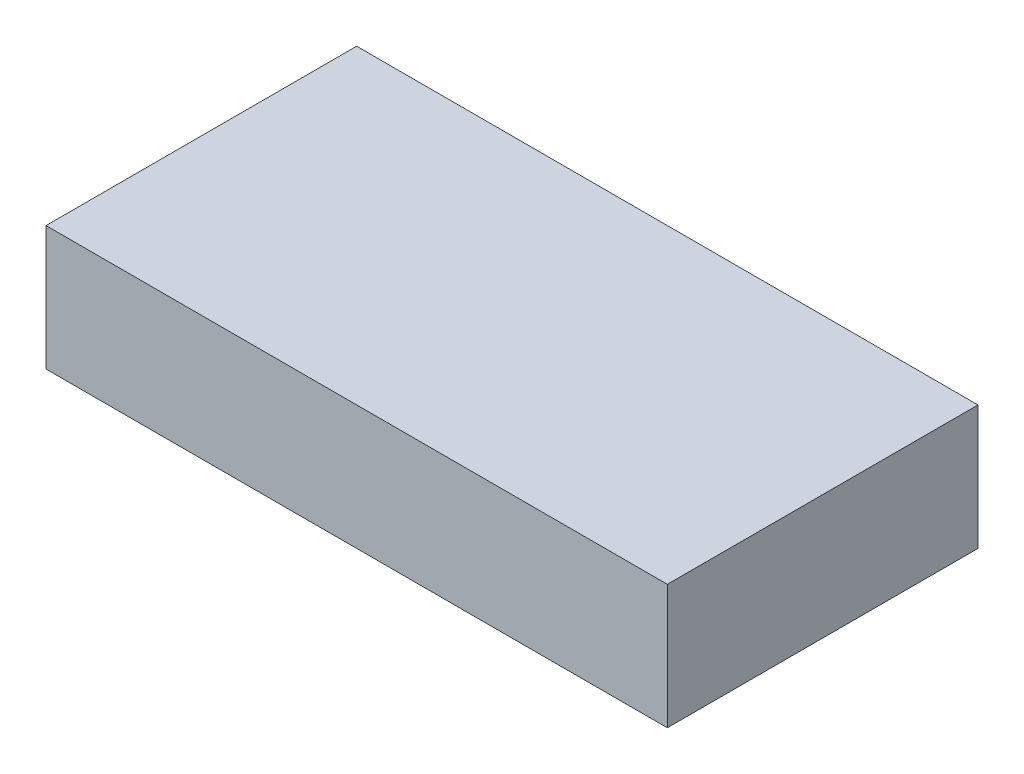
from build123d import *

# Parameters (mm, degrees)
SKETCH1_W           = 20
SKETCH1_H           = 4
BOSS_EXTRUDE1_DEPTH = 10
SKETCH2_R           = 4
BOSS_EXTRUDE2_DEPTH = 1
SKETCH5_R           = 3.5
CUT_EXTRUDE1_DEPTH  = 0.25
SKETCH6_R           = 0.25
BOSS_EXTRUDE3_DEPTH = 0.25


with BuildPart() as part:
    # Sketch1 → Boss-Extrude1 (new body)
    with BuildSketch(Plane.XY):
        Rectangle(SKETCH1_W, SKETCH1_H)
    extrude(amount=BOSS_EXTRUDE1_DEPTH)

    # Sketch2 → Boss-Extrude2 (add)
    with BuildSketch(Plane(origin=(0, -2, 0), x_dir=(-1, 0, 0), z_dir=(0, -1, 0))):
        with Locations((0, -5)):
            Circle(SKETCH2_R)
    extrude(amount=BOSS_EXTRUDE2_DEPTH)

    # Sketch5 → Cut-Extrude1 (cut)
    with BuildSketch(Plane(origin=(0, -3, 0), x_dir=(-1, 0, 0), z_dir=(0, -1, 0))):
        with Locations((0, -5)):
            Circle(SKETCH5_R)
    extrude(amount=-CUT_EXTRUDE1_DEPTH, mode=Mode.SUBTRACT)

    # Sketch6 → Boss-Extrude3 (add)
    with BuildSketch(Plane(origin=(0, -2, 0), x_dir=(-1, 0, 0), z_dir=(0, -1, 0))):
        with Locations((-7.25, -9.25)):
            Circle(SKETCH6_R)
        with Locations((-8.25, -9.25)):
            Circle(SKETCH6_R)
        with Locations((-9.25, -9.25)):
            Circle(SKETCH6_R)
    extrude(amount=BOSS_EXTRUDE3_DEPTH)


solid = part.part
